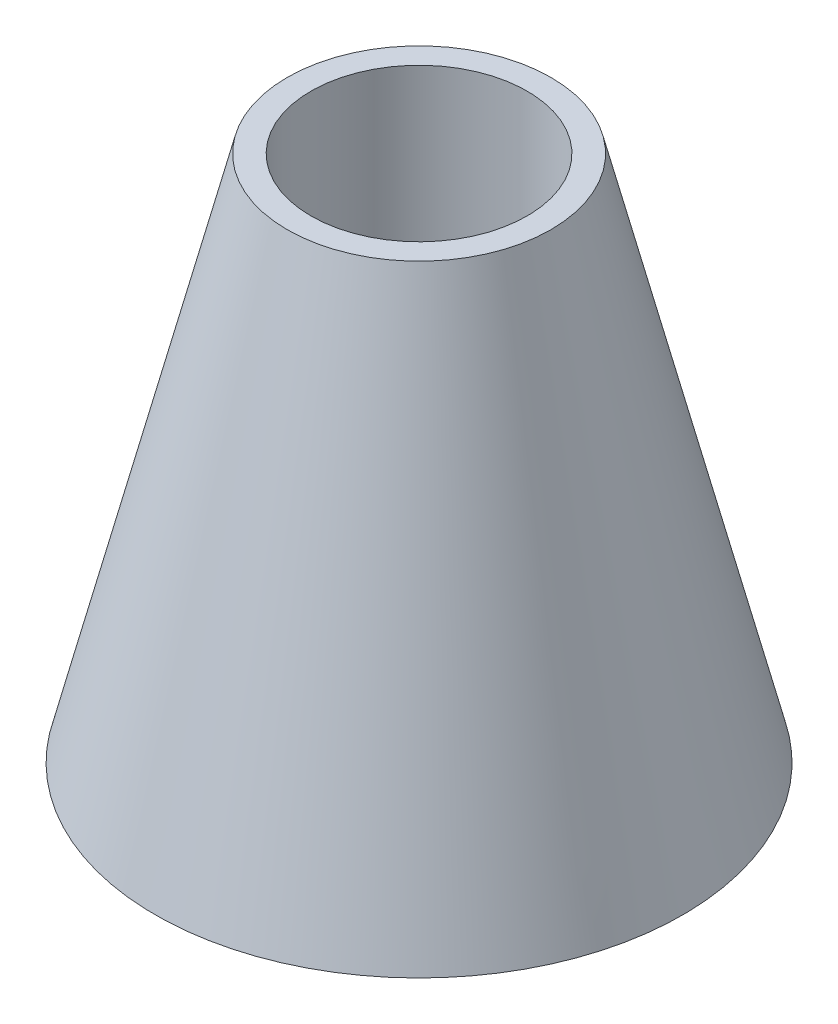
from build123d import *

# Parameters (mm, degrees)
SKETCH5_R               = 41
CUT_EXTRUDE2_DEPTH      = 200
SKETCH10_R              = 99
SKETCH10_R_2            = 42
CUT_EXTRUDE3_DEPTH      = 1
CUT_EXTRUDE3_DEPTH_BACK = 2.1


with BuildPart() as part:
    # Sketch3 → Revolve1 (revolve)
    with BuildSketch(Plane(origin=(0, 0, 0), x_dir=(0, 0, -1), z_dir=(1, 0, 0))):
        Polygon((0, 0), (100, 0), (50, 200), (0, 200), align=None)
    revolve(axis=Axis((0, 0, 0), (0, 1, 0)))

    # Sketch5 → Cut-Extrude2 (cut)
    with BuildSketch(Plane(origin=(0, 0, 0), x_dir=(1, 0, 0), z_dir=(0, 1, 0))):
        Circle(SKETCH5_R)
    extrude(amount=CUT_EXTRUDE2_DEPTH, mode=Mode.SUBTRACT)

    # Sketch7 → Cut-Revolve1 (revolve, cut)
    with BuildSketch(Plane(origin=(0, 0, 0), x_dir=(0, 0, -1), z_dir=(1, 0, 0))):
        Polygon((96.923058984, 2), (48.048058984, 197.5), (42.5, 197.5), (42.5, 2), align=None)
    revolve(axis=Axis((0, 0, 0), (0, -1, 0)), mode=Mode.SUBTRACT)

    # Sketch10 → Cut-Extrude3 (cut, two sides)
    with BuildSketch(Plane.XZ) as cut_extrude3_sk:
        Circle(SKETCH10_R)
        Circle(SKETCH10_R_2, mode=Mode.SUBTRACT)
    extrude(amount=CUT_EXTRUDE3_DEPTH, mode=Mode.SUBTRACT)
    extrude(cut_extrude3_sk.sketch, amount=-CUT_EXTRUDE3_DEPTH_BACK, mode=Mode.SUBTRACT)


solid = part.part
